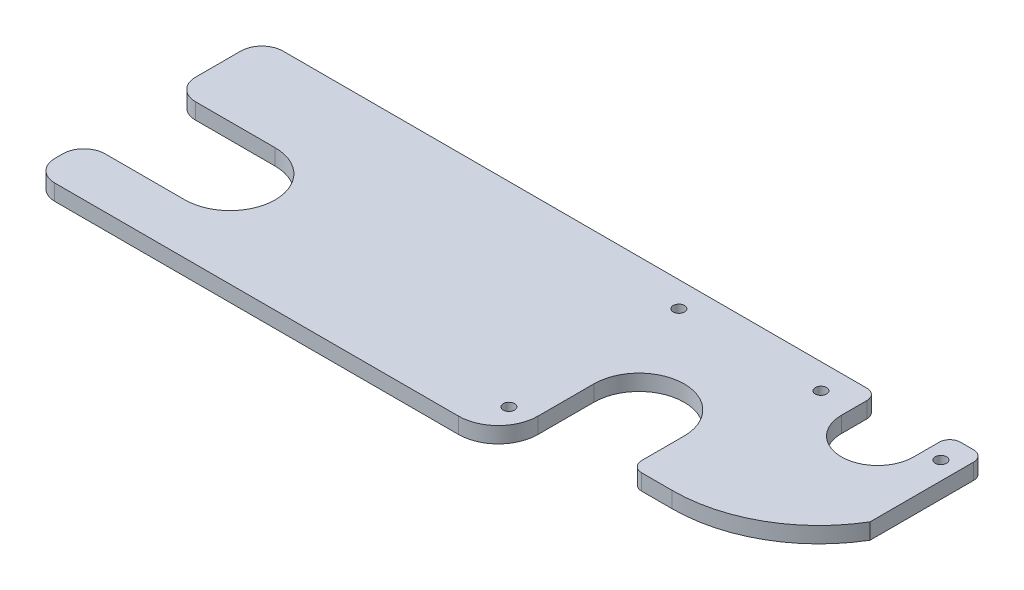
from build123d import *

# Parameters (mm, degrees)
BOSS_EXTRUDE2_DEPTH     = 9.525
CUT_EXTRUDE2_DEPTH      = 10.525
F_1_4_CLEARANCE_HOLE1_D = 6.7564
FILLET5_R               = 23.8125
FILLET6_R               = 12.7
FILLET7_R               = 6.35


with BuildPart() as part:
    # Sketch1 → Boss-Extrude2 (new body)
    with BuildSketch(Plane(origin=(0, 0, 0), x_dir=(1, 0, 0), z_dir=(0, 1, 0))):
        with BuildLine():
            Line((25.4, 0), (277.8125, 0))
            Line((277.8125, 0), (277.8125, 57.15))
            ThreePointArc((277.8125, 57.15), (304.8, 84.1375), (331.78749993, 57.15))
            Line((331.78749993, 57.15), (331.78749993, 0))
            Line((331.78749993, 0), (357.18749993, 0))
            ThreePointArc((357.18749993, 0), (407.751306336, 19.640432558), (431.8, 68.2625))
            Line((431.8, 68.2625), (431.8, 136.525))
            Line((431.8, 136.525), (411.226, 136.525))
            Line((411.226, 136.525), (411.226, 114.935))
            ThreePointArc((411.226, 114.935), (389.636, 93.345), (368.046, 114.935))
            Line((368.046, 114.935), (368.046, 136.525))
            Line((368.046, 136.525), (23.8125, 136.525))
            Line((23.8125, 136.525), (12.7, 136.525))
            ThreePointArc((12.7, 136.525), (3.719743879, 132.805256121), (0, 123.825))
            Line((0, 123.825), (0, 96.8375))
            Line((0, 96.8375), (0, 84.1375))
            Line((0, 84.1375), (22.225, 84.1375))
            Line((22.225, 84.1375), (60.325, 84.1375))
            ThreePointArc((60.325, 84.1375), (79.408044257, 76.233044257), (87.3125, 57.15))
            ThreePointArc((87.3125, 57.15), (79.408044257, 38.066955743), (60.325, 30.1625))
            Line((60.325, 30.1625), (22.225, 30.1625))
            Line((22.225, 30.1625), (0, 30.1625))
            Line((0, 30.1625), (0, 17.4625))
            Line((0, 17.4625), (0, 12.7))
            ThreePointArc((0, 12.7), (3.719743879, 3.719743879), (12.7, 0))
            Line((12.7, 0), (25.4, 0))
        make_face()
    extrude(amount=BOSS_EXTRUDE2_DEPTH)

    # Sketch2 → Cut-Extrude2 (cut, through all)
    with BuildSketch(Plane(origin=(0, 9.525, 0), x_dir=(1, 0, 0), z_dir=(0, 1, 0))):
        with BuildLine():
            Line((331.78749993, 0), (331.78749993, 25.4))
            Line((331.78749993, 25.4), (356.39375, 25.4))
            ThreePointArc((356.39375, 25.4), (399.762219091, 36.86444095), (431.8, 68.2625))
            ThreePointArc((431.8, 68.2625), (407.751306336, 19.640432558), (357.18749993, 0))
            Line((357.18749993, 0), (331.78749993, 0))
        make_face()
    extrude(amount=-CUT_EXTRUDE2_DEPTH, mode=Mode.SUBTRACT)

    # 1/4 Clearance Hole1 (through all)
    with Locations(Plane(origin=(0, 9.525, 0), x_dir=(1, 0, 0), z_dir=(0, 1, 0))):
        with Locations((420.9542, 121.44375), (349.26905, 121.44375), (264.318750035, 121.44375), (264.318750035, 19.84375)):
            Hole(F_1_4_CLEARANCE_HOLE1_D / 2)

    # Fillet5
    fillet5_edges = [part.edges().sort_by_distance(p)[0] for p in [
        (277.8125, 4.7625, 0),
    ]]
    fillet(fillet5_edges, radius=FILLET5_R)

    # Fillet6
    fillet6_edges = [part.edges().sort_by_distance(p)[0] for p in [
        (0, 4.7625, -84.1375),
        (0, 4.7625, -30.1625),
    ]]
    fillet(fillet6_edges, radius=FILLET6_R)

    # Fillet7
    fillet7_edges = [part.edges().sort_by_distance(p)[0] for p in [
        (431.8, 4.7625, -136.525),
        (411.226, 4.7625, -136.525),
        (368.046, 4.7625, -136.525),
        (331.78749993, 4.7625, -25.4),
    ]]
    fillet(fillet7_edges, radius=FILLET7_R)


solid = part.part
